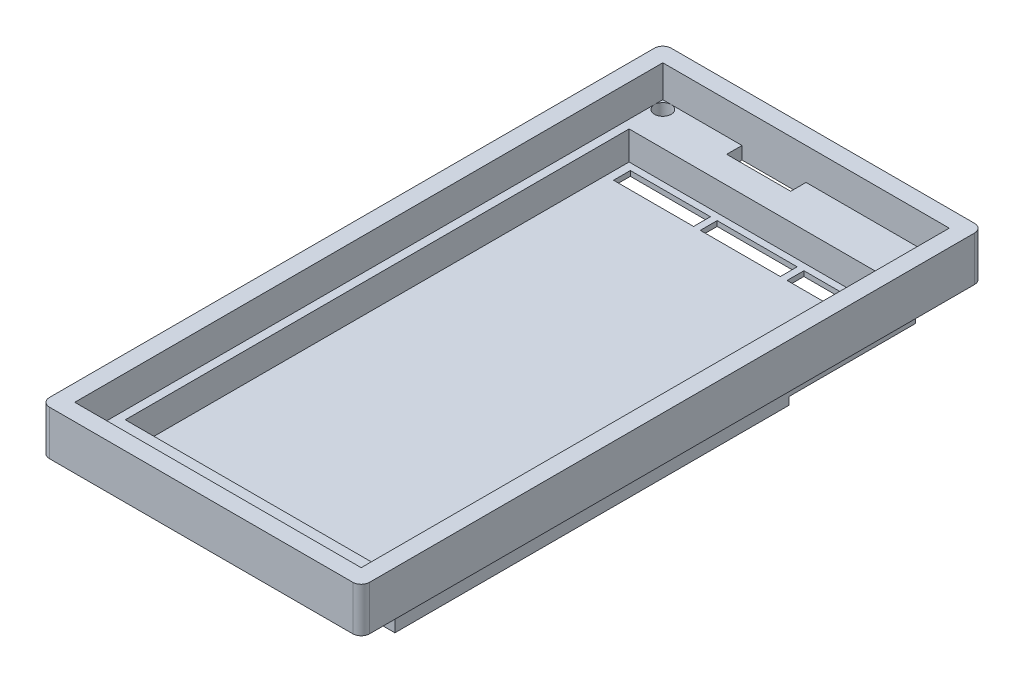
from build123d import *

# Parameters (mm, degrees)
SKETCH1_W           = 38
SKETCH1_H           = 73.8
BOSS_EXTRUDE1_DEPTH = 1.5
SKETCH2_W           = 38
SKETCH2_H           = 73.8
SKETCH2_W_2         = 34
SKETCH2_H_2         = 69.8
BOSS_EXTRUDE2_DEPTH = 3.8
FILLET1_R           = 1
SKETCH3_R           = 1
CUT_EXTRUDE1_DEPTH  = 42.67793181
SKETCH4_W           = 7.6
SKETCH4_H           = 1.82
CUT_EXTRUDE2_DEPTH  = 42.67793181
SKETCH5_W           = 9.5
SKETCH5_H           = 2
CUT_EXTRUDE3_DEPTH  = 42.67793181
LPATTERN1_COUNT     = 2
LPATTERN1_PITCH     = 56
SKETCH6_W           = 34
SKETCH6_H           = 61.8
SKETCH6_W_2         = 9.5
SKETCH6_H_2         = 2
BOSS_EXTRUDE3_DEPTH = 3.4
SKETCH7_W           = 32
SKETCH7_H           = 59.8
CUT_EXTRUDE5_DEPTH  = 3.4
SKETCH9_W           = 15
SKETCH9_H           = 0.9
CUT_EXTRUDE7_DEPTH  = 52.823739734
SKETCH10_W          = 10
SKETCH10_H          = 0.5
CUT_EXTRUDE8_DEPTH  = 7


with BuildPart() as part:
    # Sketch1 → Boss-Extrude1 (new body)
    with BuildSketch(Plane(origin=(0, 0, 0), x_dir=(1, 0, 0), z_dir=(0, 1, 0))):
        Rectangle(SKETCH1_W, SKETCH1_H)
    extrude(amount=BOSS_EXTRUDE1_DEPTH)

    # Sketch2 → Boss-Extrude2 (add)
    with BuildSketch(Plane(origin=(0, 1.5, 0), x_dir=(1, 0, 0), z_dir=(0, 1, 0))):
        Rectangle(SKETCH2_W, SKETCH2_H)
        Rectangle(SKETCH2_W_2, SKETCH2_H_2, mode=Mode.SUBTRACT)
    extrude(amount=BOSS_EXTRUDE2_DEPTH)

    # Fillet1
    fillet1_edges = [part.edges().sort_by_distance(p)[0] for p in [
        (19, 2.65, -36.9),
        (-19, 2.65, -36.9),
        (19, 2.65, 36.9),
        (-19, 2.65, 36.9),
    ]]
    fillet(fillet1_edges, radius=FILLET1_R)

    # Sketch3 → Cut-Extrude1 (cut, through all)
    with BuildSketch(Plane(origin=(0, 1.5, 0), x_dir=(1, 0, 0), z_dir=(0, 1, 0))):
        with Locations((-16, 33.9)):
            Circle(SKETCH3_R)
        with Locations((16, 33.9)):
            Circle(SKETCH3_R)
    cut_extrude1 = extrude(amount=-CUT_EXTRUDE1_DEPTH, mode=Mode.SUBTRACT)

    # Mirror1: Cut-Extrude1 across plane
    add(cut_extrude1.mirror(Plane.XY), mode=Mode.SUBTRACT)

    # Sketch4 → Cut-Extrude2 (cut, through all)
    with BuildSketch(Plane(origin=(0, 1.5, 0), x_dir=(1, 0, 0), z_dir=(0, 1, 0))):
        with Locations((-3.8, 33.99)):
            Rectangle(SKETCH4_W, SKETCH4_H)
    extrude(amount=-CUT_EXTRUDE2_DEPTH, mode=Mode.SUBTRACT)

    # Sketch5 → Cut-Extrude3 (cut, through all)
    with BuildSketch(Plane(origin=(0, 1.5, 0), x_dir=(1, 0, 0), z_dir=(0, 1, 0))):
        with Locations((-10.3, 28.1)):
            Rectangle(SKETCH5_W, SKETCH5_H)
        with Locations((0, 28.1)):
            Rectangle(SKETCH5_W, SKETCH5_H)
        with Locations((10.3, 28.1)):
            Rectangle(SKETCH5_W, SKETCH5_H)
    cut_extrude3 = extrude(amount=-CUT_EXTRUDE3_DEPTH, mode=Mode.SUBTRACT)

    # LPattern1: Cut-Extrude3 ×2
    with Locations(*[(0, 0, i * LPATTERN1_PITCH) for i in range(1, LPATTERN1_COUNT)]):
        add(cut_extrude3, mode=Mode.SUBTRACT)

    # Sketch6 → Boss-Extrude3 (add)
    with BuildSketch(Plane.XZ):
        Rectangle(SKETCH6_W, SKETCH6_H)
        with Locations((-10.3, 27.9)):
            Rectangle(SKETCH6_W_2, SKETCH6_H_2, mode=Mode.SUBTRACT)
        with Locations((0, 27.9)):
            Rectangle(SKETCH6_W_2, SKETCH6_H_2, mode=Mode.SUBTRACT)
        with Locations((10.3, 27.9)):
            Rectangle(SKETCH6_W_2, SKETCH6_H_2, mode=Mode.SUBTRACT)
        with Locations((-10.3, -28.1)):
            Rectangle(SKETCH6_W_2, SKETCH6_H_2, mode=Mode.SUBTRACT)
        with Locations((0, -28.1)):
            Rectangle(SKETCH6_W_2, SKETCH6_H_2, mode=Mode.SUBTRACT)
        with Locations((10.3, -28.1)):
            Rectangle(SKETCH6_W_2, SKETCH6_H_2, mode=Mode.SUBTRACT)
    extrude(amount=BOSS_EXTRUDE3_DEPTH)

    # Sketch7 → Cut-Extrude5 (cut)
    with BuildSketch(Plane(origin=(0, 1.5, 0), x_dir=(1, 0, 0), z_dir=(0, 1, 0))):
        Rectangle(SKETCH7_W, SKETCH7_H)
    extrude(amount=-CUT_EXTRUDE5_DEPTH, mode=Mode.SUBTRACT)

    # Sketch9 → Cut-Extrude7 (cut, through all)
    with BuildSketch(Plane(origin=(17, 0, 0), x_dir=(0, 0, -1), z_dir=(1, 0, 0))):
        with Locations((23.4, -2.95)):
            Rectangle(SKETCH9_W, SKETCH9_H)
    extrude(amount=-CUT_EXTRUDE7_DEPTH, mode=Mode.SUBTRACT)

    # Sketch10 → Cut-Extrude8 (cut)
    with BuildSketch(Plane.ZY.offset(17)):
        with Locations((-4.1, -3.15)):
            Rectangle(SKETCH10_W, SKETCH10_H)
    extrude(amount=-CUT_EXTRUDE8_DEPTH, mode=Mode.SUBTRACT)


solid = part.part
